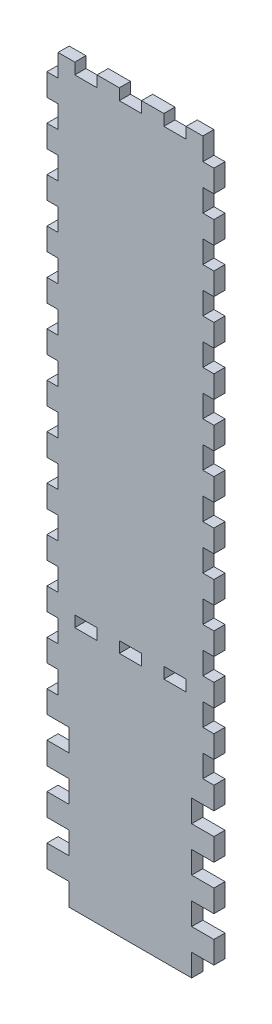
from build123d import *

# Parameters (mm, degrees)
SKETCH2_W           = 95.25
SKETCH2_H           = 419.1
BOSS_EXTRUDE1_DEPTH = 6.35
SKETCH3_W           = 6.35
SKETCH3_H           = 12.7
CUT_EXTRUDE1_DEPTH  = 7.35
LPATTERN1_COUNT     = 17
LPATTERN1_PITCH     = 25.4
SKETCH4_W           = 12.7
SKETCH4_H           = 6.35
CUT_EXTRUDE2_DEPTH  = 7.35
SKETCH5_W           = 6.35
SKETCH5_H           = 12.7
CUT_EXTRUDE3_DEPTH  = 7.35
LPATTERN2_COUNT     = 4
LPATTERN2_PITCH     = 25.4
SKETCH6_W           = 12.7
SKETCH6_H           = 6.35
CUT_EXTRUDE4_DEPTH  = 7.35
LPATTERN3_COUNT     = 2
LPATTERN3_PITCH     = 25.4
LPATTERN3_COL_COUNT = 2
LPATTERN3_COL_PITCH = 25.4


with BuildPart() as part:
    # Sketch2 → Boss-Extrude1 (new body)
    with BuildSketch(Plane.XY):
        with Locations((47.625, 209.55)):
            Rectangle(SKETCH2_W, SKETCH2_H)
    extrude(amount=BOSS_EXTRUDE1_DEPTH)

    # Sketch3 → Cut-Extrude1 (cut, through all)
    with BuildSketch(Plane.XY.offset(6.35)):
        with Locations((3.175, 6.35)):
            Rectangle(SKETCH3_W, SKETCH3_H)
        with Locations((92.075, 6.35)):
            Rectangle(SKETCH3_W, SKETCH3_H)
    cut_extrude1 = extrude(amount=-CUT_EXTRUDE1_DEPTH, mode=Mode.SUBTRACT)

    # LPattern1: Cut-Extrude1 ×17
    with Locations(*[(0, i * LPATTERN1_PITCH, 0) for i in range(1, LPATTERN1_COUNT)]):
        add(cut_extrude1, mode=Mode.SUBTRACT)

    # Sketch4 → Cut-Extrude2 (cut, through all)
    with BuildSketch(Plane.XY.offset(6.35)):
        with Locations((47.625, 415.925)):
            Rectangle(SKETCH4_W, SKETCH4_H)
        with Locations((22.225, 415.925)):
            Rectangle(SKETCH4_W, SKETCH4_H)
        with Locations((73.025, 415.925)):
            Rectangle(SKETCH4_W, SKETCH4_H)
    extrude(amount=-CUT_EXTRUDE2_DEPTH, mode=Mode.SUBTRACT)

    # Sketch5 → Cut-Extrude3 (cut, through all)
    with BuildSketch(Plane.XY.offset(6.35)):
        with Locations((9.525, 6.35)):
            Rectangle(SKETCH5_W, SKETCH5_H)
        with Locations((85.725, 6.35)):
            Rectangle(SKETCH5_W, SKETCH5_H)
    cut_extrude3 = extrude(amount=-CUT_EXTRUDE3_DEPTH, mode=Mode.SUBTRACT)

    # LPattern2: Cut-Extrude3 ×4
    with Locations(*[(0, i * LPATTERN2_PITCH, 0) for i in range(1, LPATTERN2_COUNT)]):
        add(cut_extrude3, mode=Mode.SUBTRACT)

    # Sketch6 → Cut-Extrude4 (cut, through all)
    with BuildSketch(Plane.XY.offset(6.35)):
        with Locations((47.625, 142.875)):
            Rectangle(SKETCH6_W, SKETCH6_H)
    cut_extrude4 = extrude(amount=-CUT_EXTRUDE4_DEPTH, mode=Mode.SUBTRACT)

    # LPattern3: Cut-Extrude4 ×2
    with Locations(*[(i * LPATTERN3_PITCH, 0, 0) for i in range(1, LPATTERN3_COUNT)]):
        add(cut_extrude4, mode=Mode.SUBTRACT)

    # LPattern3 col: Cut-Extrude4 ×2
    with Locations(*[(-i * LPATTERN3_COL_PITCH, 0, 0) for i in range(1, LPATTERN3_COL_COUNT)]):
        add(cut_extrude4, mode=Mode.SUBTRACT)


solid = part.part
